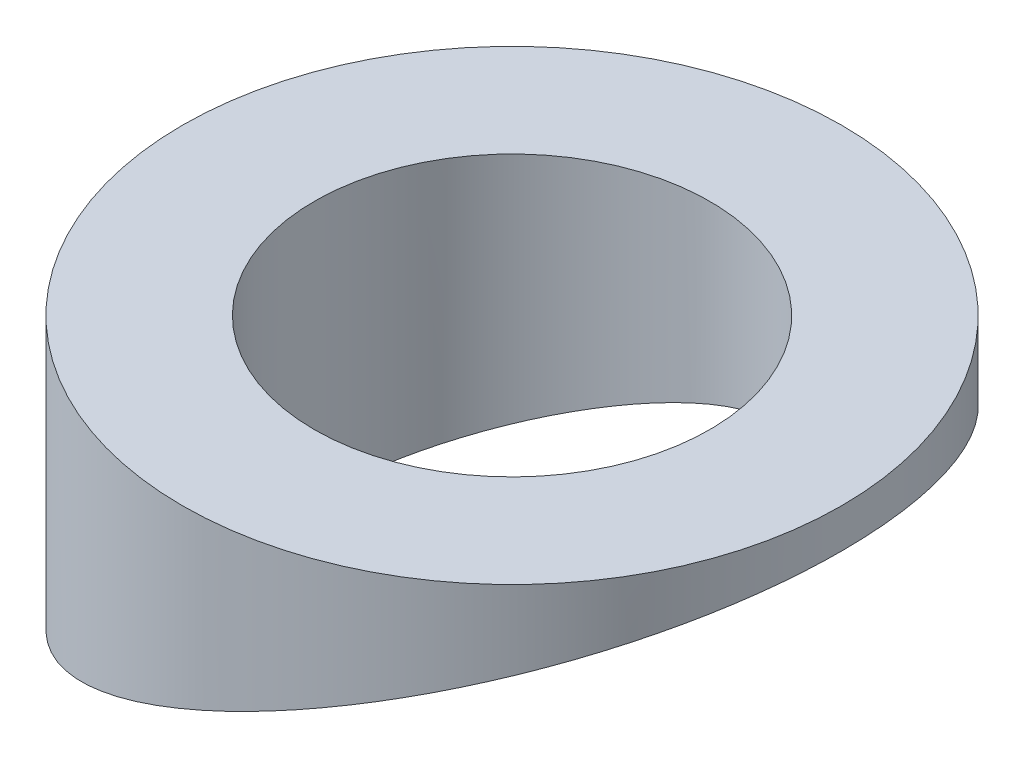
from build123d import *

# Parameters (mm, degrees)
SKETCH_1_R          = 15
EXTRUDE_1_DEPTH     = 20
CUT_EXTRUDE_1_DEPTH = 16.5
SKETCH_10_R         = 9
CUT_EXTRUDE_2_DEPTH = 24.5


with BuildPart() as part:
    # 草图1 → 凸台-拉伸1 (new body)
    with BuildSketch(Plane(origin=(0, 0, 0), x_dir=(1, 0, 0), z_dir=(0, 1, 0))):
        Circle(SKETCH_1_R)
    extrude(amount=EXTRUDE_1_DEPTH)

    # 草图2 → 切除-拉伸1 (cut, symmetric)
    with BuildSketch(Plane.XY):
        Polygon((-15, 5.786796564), (15, 18.213203436), (15, -10.377528432), (-15, -10.377528432), align=None)
    extrude(amount=CUT_EXTRUDE_1_DEPTH, both=True, mode=Mode.SUBTRACT)

    # 草图10 → 切除-拉伸2 (cut)
    with BuildSketch(Plane(origin=(0, 20, 0), x_dir=(1, 0, 0), z_dir=(0, 1, 0))):
        Circle(SKETCH_10_R)
    extrude(amount=-CUT_EXTRUDE_2_DEPTH, mode=Mode.SUBTRACT)


solid = part.part
